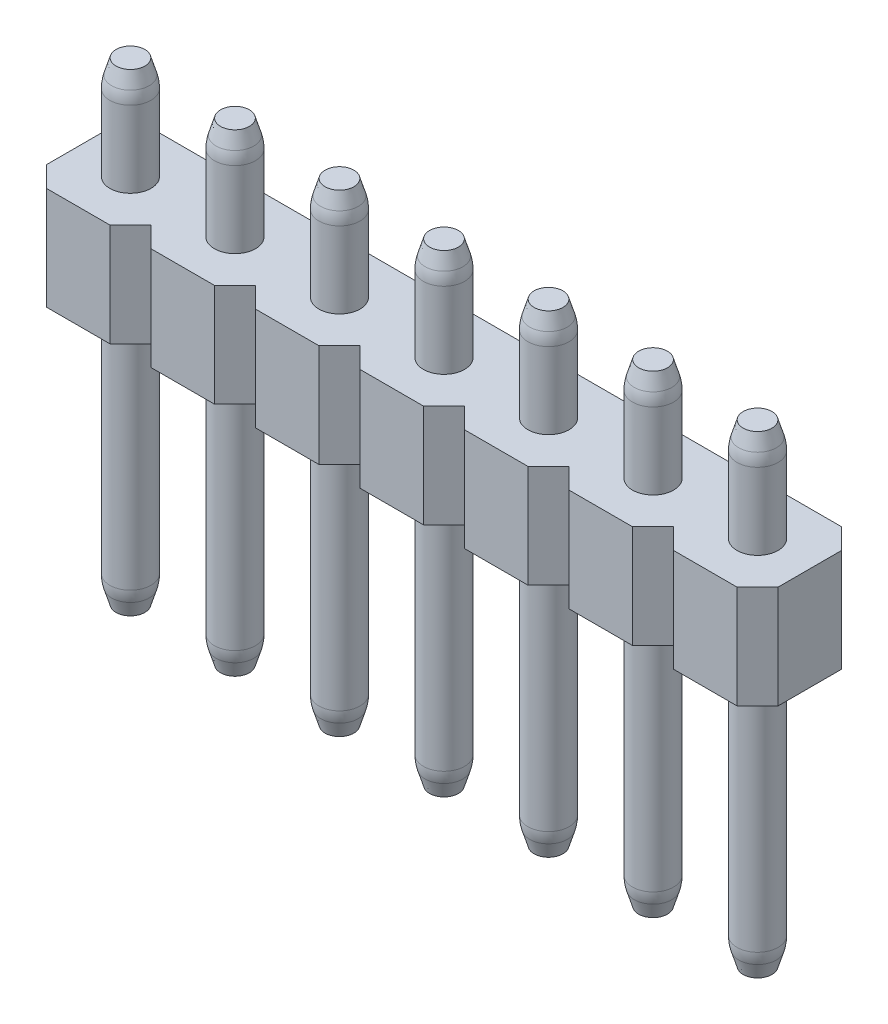
from build123d import *

# Parameters (mm, degrees)
SKETCH1_R               = 0.5
BOSS_EXTRUDE1_DEPTH     = 11.5
BOSS_EXTRUDE1_2_DEPTH   = 11.5
BOSS_EXTRUDE1_3_DEPTH   = 11.5
BOSS_EXTRUDE1_4_DEPTH   = 11.5
BOSS_EXTRUDE1_5_DEPTH   = 11.5
BOSS_EXTRUDE1_6_DEPTH   = 11.5
BOSS_EXTRUDE1_7_DEPTH   = 11.5
BOSS_EXTRUDE1_8_DEPTH   = 11.5
BOSS_EXTRUDE1_9_DEPTH   = 11.5
BOSS_EXTRUDE1_10_DEPTH  = 11.5
BOSS_EXTRUDE1_11_DEPTH  = 11.5
BOSS_EXTRUDE1_12_DEPTH  = 11.5
BOSS_EXTRUDE1_13_DEPTH  = 11.5
BOSS_EXTRUDE1_14_DEPTH  = 11.5
BOSS_EXTRUDE1_15_DEPTH  = 11.5
BOSS_EXTRUDE1_16_DEPTH  = 11.5
BOSS_EXTRUDE2_DEPTH     = 2.5
CHAMFER1_SIZE           = 0.5
CHAMFER1_SIZE2          = 0.15
CHAMFER1_PART_2_SIZE    = 0.5
CHAMFER1_PART_2_SIZE2   = 0.15
CHAMFER1_PART_3_SIZE    = 0.5
CHAMFER1_PART_3_SIZE2   = 0.15
CHAMFER1_PART_4_SIZE    = 0.5
CHAMFER1_PART_4_SIZE2   = 0.15
CHAMFER1_PART_5_SIZE    = 0.5
CHAMFER1_PART_5_SIZE2   = 0.15
CHAMFER1_PART_6_SIZE    = 0.5
CHAMFER1_PART_6_SIZE2   = 0.15
CHAMFER1_PART_7_SIZE    = 0.5
CHAMFER1_PART_7_SIZE2   = 0.15
CHAMFER1_PART_8_SIZE    = 0.5
CHAMFER1_PART_8_SIZE2   = 0.15
CHAMFER1_PART_9_SIZE    = 0.5
CHAMFER1_PART_9_SIZE2   = 0.15
CHAMFER1_PART_10_SIZE   = 0.5
CHAMFER1_PART_10_SIZE2  = 0.15
CHAMFER1_PART_11_SIZE   = 0.5
CHAMFER1_PART_11_SIZE2  = 0.15
CHAMFER1_PART_12_SIZE   = 0.5
CHAMFER1_PART_12_SIZE2  = 0.15
CHAMFER1_PART_13_SIZE   = 0.5
CHAMFER1_PART_13_SIZE2  = 0.15
CHAMFER1_PART_14_SIZE   = 0.5
CHAMFER1_PART_14_SIZE2  = 0.15
CHAMFER1_PART_15_SIZE   = 0.5
CHAMFER1_PART_15_SIZE2  = 0.15
CHAMFER1_PART_16_SIZE   = 0.5
CHAMFER1_PART_16_SIZE2  = 0.15
FILLET1_R               = 1
CHAMFER2_SIZE           = 0.15
CHAMFER2_SIZE2          = 0.5
CHAMFER2_PART_2_SIZE    = 0.15
CHAMFER2_PART_2_SIZE2   = 0.5
CHAMFER2_PART_3_SIZE    = 0.15
CHAMFER2_PART_3_SIZE2   = 0.5
CHAMFER2_PART_4_SIZE    = 0.15
CHAMFER2_PART_4_SIZE2   = 0.5
CHAMFER2_PART_5_SIZE    = 0.15
CHAMFER2_PART_5_SIZE2   = 0.5
CHAMFER2_PART_6_SIZE    = 0.15
CHAMFER2_PART_6_SIZE2   = 0.5
CHAMFER2_PART_7_SIZE    = 0.15
CHAMFER2_PART_7_SIZE2   = 0.5
CHAMFER2_PART_8_SIZE    = 0.15
CHAMFER2_PART_8_SIZE2   = 0.5
CHAMFER2_PART_9_SIZE    = 0.15
CHAMFER2_PART_9_SIZE2   = 0.5
CHAMFER2_PART_10_SIZE   = 0.15
CHAMFER2_PART_10_SIZE2  = 0.5
CHAMFER2_PART_11_SIZE   = 0.15
CHAMFER2_PART_11_SIZE2  = 0.5
CHAMFER2_PART_12_SIZE   = 0.15
CHAMFER2_PART_12_SIZE2  = 0.5
CHAMFER2_PART_13_SIZE   = 0.15
CHAMFER2_PART_13_SIZE2  = 0.5
CHAMFER2_PART_14_SIZE   = 0.15
CHAMFER2_PART_14_SIZE2  = 0.5
CHAMFER2_PART_15_SIZE   = 0.15
CHAMFER2_PART_15_SIZE2  = 0.5
CHAMFER2_PART_16_SIZE   = 0.15
CHAMFER2_PART_16_SIZE2  = 0.5
FILLET2_R               = 1
SKETCH3_W               = 22.86
SKETCH3_H               = 11.5
CUT_EXTRUDE1_DEPTH      = 1
CUT_EXTRUDE1_DEPTH_BACK = 3.54


with BuildPart() as part:
    # Sketch1 → Boss-Extrude1 (new body)
    with BuildSketch(Plane(origin=(0, 0, 0), x_dir=(1, 0, 0), z_dir=(0, 1, 0))):
        Circle(SKETCH1_R)
    extrude(amount=BOSS_EXTRUDE1_DEPTH)



with BuildPart() as body_2:
    # Sketch1 → Boss-Extrude1 2 (new body)
    with BuildSketch(Plane(origin=(0, 0, 0), x_dir=(1, 0, 0), z_dir=(0, 1, 0))):
        with Locations((2.54, 0)):
            Circle(SKETCH1_R)
    extrude(amount=BOSS_EXTRUDE1_2_DEPTH)


with BuildPart() as body_3:
    # Sketch1 → Boss-Extrude1 3 (new body)
    with BuildSketch(Plane(origin=(0, 0, 0), x_dir=(1, 0, 0), z_dir=(0, 1, 0))):
        with Locations((5.08, 0)):
            Circle(SKETCH1_R)
    extrude(amount=BOSS_EXTRUDE1_3_DEPTH)


with BuildPart() as body_4:
    # Sketch1 → Boss-Extrude1 4 (new body)
    with BuildSketch(Plane(origin=(0, 0, 0), x_dir=(1, 0, 0), z_dir=(0, 1, 0))):
        with Locations((7.62, 0)):
            Circle(SKETCH1_R)
    extrude(amount=BOSS_EXTRUDE1_4_DEPTH)


with BuildPart() as body_5:
    # Sketch1 → Boss-Extrude1 5 (new body)
    with BuildSketch(Plane(origin=(0, 0, 0), x_dir=(1, 0, 0), z_dir=(0, 1, 0))):
        with Locations((10.16, 0)):
            Circle(SKETCH1_R)
    extrude(amount=BOSS_EXTRUDE1_5_DEPTH)


with BuildPart() as body_6:
    # Sketch1 → Boss-Extrude1 6 (new body)
    with BuildSketch(Plane(origin=(0, 0, 0), x_dir=(1, 0, 0), z_dir=(0, 1, 0))):
        with Locations((12.7, 0)):
            Circle(SKETCH1_R)
    extrude(amount=BOSS_EXTRUDE1_6_DEPTH)


with BuildPart() as body_7:
    # Sketch1 → Boss-Extrude1 7 (new body)
    with BuildSketch(Plane(origin=(0, 0, 0), x_dir=(1, 0, 0), z_dir=(0, 1, 0))):
        with Locations((15.24, 0)):
            Circle(SKETCH1_R)
    extrude(amount=BOSS_EXTRUDE1_7_DEPTH)


with BuildPart() as body_8:
    # Sketch1 → Boss-Extrude1 8 (new body)
    with BuildSketch(Plane(origin=(0, 0, 0), x_dir=(1, 0, 0), z_dir=(0, 1, 0))):
        with Locations((17.78, 0)):
            Circle(SKETCH1_R)
    extrude(amount=BOSS_EXTRUDE1_8_DEPTH)


with BuildPart() as body_9:
    # Sketch1 → Boss-Extrude1 9 (new body)
    with BuildSketch(Plane(origin=(0, 0, 0), x_dir=(1, 0, 0), z_dir=(0, 1, 0))):
        with Locations((20.32, 0)):
            Circle(SKETCH1_R)
    extrude(amount=BOSS_EXTRUDE1_9_DEPTH)


with BuildPart() as body_10:
    # Sketch1 → Boss-Extrude1 10 (new body)
    with BuildSketch(Plane(origin=(0, 0, 0), x_dir=(1, 0, 0), z_dir=(0, 1, 0))):
        with Locations((22.86, 0)):
            Circle(SKETCH1_R)
    extrude(amount=BOSS_EXTRUDE1_10_DEPTH)


with BuildPart() as body_11:
    # Sketch1 → Boss-Extrude1 11 (new body)
    with BuildSketch(Plane(origin=(0, 0, 0), x_dir=(1, 0, 0), z_dir=(0, 1, 0))):
        with Locations((25.4, 0)):
            Circle(SKETCH1_R)
    extrude(amount=BOSS_EXTRUDE1_11_DEPTH)


with BuildPart() as body_12:
    # Sketch1 → Boss-Extrude1 12 (new body)
    with BuildSketch(Plane(origin=(0, 0, 0), x_dir=(1, 0, 0), z_dir=(0, 1, 0))):
        with Locations((27.94, 0)):
            Circle(SKETCH1_R)
    extrude(amount=BOSS_EXTRUDE1_12_DEPTH)


with BuildPart() as body_13:
    # Sketch1 → Boss-Extrude1 13 (new body)
    with BuildSketch(Plane(origin=(0, 0, 0), x_dir=(1, 0, 0), z_dir=(0, 1, 0))):
        with Locations((30.48, 0)):
            Circle(SKETCH1_R)
    extrude(amount=BOSS_EXTRUDE1_13_DEPTH)


with BuildPart() as body_14:
    # Sketch1 → Boss-Extrude1 14 (new body)
    with BuildSketch(Plane(origin=(0, 0, 0), x_dir=(1, 0, 0), z_dir=(0, 1, 0))):
        with Locations((33.02, 0)):
            Circle(SKETCH1_R)
    extrude(amount=BOSS_EXTRUDE1_14_DEPTH)


with BuildPart() as body_15:
    # Sketch1 → Boss-Extrude1 15 (new body)
    with BuildSketch(Plane(origin=(0, 0, 0), x_dir=(1, 0, 0), z_dir=(0, 1, 0))):
        with Locations((35.56, 0)):
            Circle(SKETCH1_R)
    extrude(amount=BOSS_EXTRUDE1_15_DEPTH)


with BuildPart() as body_16:
    # Sketch1 → Boss-Extrude1 16 (new body)
    with BuildSketch(Plane(origin=(0, 0, 0), x_dir=(1, 0, 0), z_dir=(0, 1, 0))):
        with Locations((38.1, 0)):
            Circle(SKETCH1_R)
    extrude(amount=BOSS_EXTRUDE1_16_DEPTH)


with BuildPart() as part_1:
    add(part.part)

    add(body_2.part)  # Boss-Extrude2 merges body 2

    add(body_3.part)  # Boss-Extrude2 merges body 3

    add(body_4.part)  # Boss-Extrude2 merges body 4

    add(body_5.part)  # Boss-Extrude2 merges body 5

    add(body_6.part)  # Boss-Extrude2 merges body 6

    add(body_7.part)  # Boss-Extrude2 merges body 7

    add(body_8.part)  # Boss-Extrude2 merges body 8

    add(body_9.part)  # Boss-Extrude2 merges body 9

    add(body_10.part)  # Boss-Extrude2 merges body 10

    add(body_11.part)  # Boss-Extrude2 merges body 11

    add(body_12.part)  # Boss-Extrude2 merges body 12

    add(body_13.part)  # Boss-Extrude2 merges body 13

    add(body_14.part)  # Boss-Extrude2 merges body 14

    add(body_15.part)  # Boss-Extrude2 merges body 15

    add(body_16.part)  # Boss-Extrude2 merges body 16
    # Sketch2 → Boss-Extrude2 (add)
    with BuildSketch(Plane(origin=(0, 6.5, 0), x_dir=(1, 0, 0), z_dir=(0, 1, 0))):
        Polygon((-1.27, 0.77), (-0.77, 1.27), (0.77, 1.27), (1.27, 0.77), (1.77, 1.27), (3.31, 1.27), (3.81, 0.77), (4.31, 1.27), (5.85, 1.27), (6.35, 0.77), (6.85, 1.27), (8.39, 1.27), (8.89, 0.77), (9.39, 1.27), (10.93, 1.27), (11.43, 0.77), (11.93, 1.27), (13.47, 1.27), (13.97, 0.77), (14.47, 1.27), (16.01, 1.27), (16.51, 0.77), (17.01, 1.27), (18.55, 1.27), (19.05, 0.77), (19.55, 1.27), (21.09, 1.27), (21.59, 0.77), (22.09, 1.27), (23.63, 1.27), (24.13, 0.77), (24.63, 1.27), (26.17, 1.27), (26.67, 0.77), (27.17, 1.27), (28.71, 1.27), (29.21, 0.77), (29.71, 1.27), (31.25, 1.27), (31.75, 0.77), (32.25, 1.27), (33.79, 1.27), (34.29, 0.77), (34.79, 1.27), (36.33, 1.27), (36.83, 0.77), (37.33, 1.27), (38.87, 1.27), (39.37, 0.77), (39.37, -0.77), (38.87, -1.27), (37.33, -1.27), (36.83, -0.77), (36.33, -1.27), (34.79, -1.27), (34.29, -0.77), (33.79, -1.27), (32.25, -1.27), (31.75, -0.77), (31.25, -1.27), (29.71, -1.27), (29.21, -0.77), (28.71, -1.27), (27.17, -1.27), (26.67, -0.77), (26.17, -1.27), (24.63, -1.27), (24.13, -0.77), (23.63, -1.27), (22.09, -1.27), (21.59, -0.77), (21.09, -1.27), (19.55, -1.27), (19.05, -0.77), (18.55, -1.27), (17.01, -1.27), (16.51, -0.77), (16.01, -1.27), (14.47, -1.27), (13.97, -0.77), (13.47, -1.27), (11.93, -1.27), (11.43, -0.77), (10.93, -1.27), (9.39, -1.27), (8.89, -0.77), (8.39, -1.27), (6.85, -1.27), (6.35, -0.77), (5.85, -1.27), (4.31, -1.27), (3.81, -0.77), (3.31, -1.27), (1.77, -1.27), (1.27, -0.77), (0.77, -1.27), (-0.77, -1.27), (-1.27, -0.77), align=None)
    extrude(amount=BOSS_EXTRUDE2_DEPTH)

    # Chamfer1
    chamfer1_edges = [part_1.edges().sort_by_distance(p)[0] for p in [
        (2.04, 11.5, 0),
    ]]
    chamfer1_side = [part_1.faces().sort_by_distance(p)[0] for p in [
        (2.04, 10.25, 0),
    ]]
    chamfer(chamfer1_edges, length=CHAMFER1_SIZE, length2=CHAMFER1_SIZE2, reference=chamfer1_side[0])

    # Chamfer1 part 2
    chamfer1_part_2_edges = [part_1.edges().sort_by_distance(p)[0] for p in [
        (4.58, 11.5, 0),
    ]]
    chamfer1_part_2_side = [part_1.faces().sort_by_distance(p)[0] for p in [
        (4.58, 10.25, 0),
    ]]
    chamfer(chamfer1_part_2_edges, length=CHAMFER1_PART_2_SIZE, length2=CHAMFER1_PART_2_SIZE2, reference=chamfer1_part_2_side[0])

    # Chamfer1 part 3
    chamfer1_part_3_edges = [part_1.edges().sort_by_distance(p)[0] for p in [
        (7.12, 11.5, 0),
    ]]
    chamfer1_part_3_side = [part_1.faces().sort_by_distance(p)[0] for p in [
        (7.12, 10.25, 0),
    ]]
    chamfer(chamfer1_part_3_edges, length=CHAMFER1_PART_3_SIZE, length2=CHAMFER1_PART_3_SIZE2, reference=chamfer1_part_3_side[0])

    # Chamfer1 part 4
    chamfer1_part_4_edges = [part_1.edges().sort_by_distance(p)[0] for p in [
        (9.66, 11.5, 0),
    ]]
    chamfer1_part_4_side = [part_1.faces().sort_by_distance(p)[0] for p in [
        (9.66, 10.25, 0),
    ]]
    chamfer(chamfer1_part_4_edges, length=CHAMFER1_PART_4_SIZE, length2=CHAMFER1_PART_4_SIZE2, reference=chamfer1_part_4_side[0])

    # Chamfer1 part 5
    chamfer1_part_5_edges = [part_1.edges().sort_by_distance(p)[0] for p in [
        (12.2, 11.5, 0),
    ]]
    chamfer1_part_5_side = [part_1.faces().sort_by_distance(p)[0] for p in [
        (12.2, 10.25, 0),
    ]]
    chamfer(chamfer1_part_5_edges, length=CHAMFER1_PART_5_SIZE, length2=CHAMFER1_PART_5_SIZE2, reference=chamfer1_part_5_side[0])

    # Chamfer1 part 6
    chamfer1_part_6_edges = [part_1.edges().sort_by_distance(p)[0] for p in [
        (14.74, 11.5, 0),
    ]]
    chamfer1_part_6_side = [part_1.faces().sort_by_distance(p)[0] for p in [
        (14.74, 10.25, 0),
    ]]
    chamfer(chamfer1_part_6_edges, length=CHAMFER1_PART_6_SIZE, length2=CHAMFER1_PART_6_SIZE2, reference=chamfer1_part_6_side[0])

    # Chamfer1 part 7
    chamfer1_part_7_edges = [part_1.edges().sort_by_distance(p)[0] for p in [
        (17.28, 11.5, 0),
    ]]
    chamfer1_part_7_side = [part_1.faces().sort_by_distance(p)[0] for p in [
        (17.28, 10.25, 0),
    ]]
    chamfer(chamfer1_part_7_edges, length=CHAMFER1_PART_7_SIZE, length2=CHAMFER1_PART_7_SIZE2, reference=chamfer1_part_7_side[0])

    # Chamfer1 part 8
    chamfer1_part_8_edges = [part_1.edges().sort_by_distance(p)[0] for p in [
        (19.82, 11.5, 0),
    ]]
    chamfer1_part_8_side = [part_1.faces().sort_by_distance(p)[0] for p in [
        (19.82, 10.25, 0),
    ]]
    chamfer(chamfer1_part_8_edges, length=CHAMFER1_PART_8_SIZE, length2=CHAMFER1_PART_8_SIZE2, reference=chamfer1_part_8_side[0])

    # Chamfer1 part 9
    chamfer1_part_9_edges = [part_1.edges().sort_by_distance(p)[0] for p in [
        (22.36, 11.5, 0),
    ]]
    chamfer1_part_9_side = [part_1.faces().sort_by_distance(p)[0] for p in [
        (22.36, 10.25, 0),
    ]]
    chamfer(chamfer1_part_9_edges, length=CHAMFER1_PART_9_SIZE, length2=CHAMFER1_PART_9_SIZE2, reference=chamfer1_part_9_side[0])

    # Chamfer1 part 10
    chamfer1_part_10_edges = [part_1.edges().sort_by_distance(p)[0] for p in [
        (24.9, 11.5, 0),
    ]]
    chamfer1_part_10_side = [part_1.faces().sort_by_distance(p)[0] for p in [
        (24.9, 10.25, 0),
    ]]
    chamfer(chamfer1_part_10_edges, length=CHAMFER1_PART_10_SIZE, length2=CHAMFER1_PART_10_SIZE2, reference=chamfer1_part_10_side[0])

    # Chamfer1 part 11
    chamfer1_part_11_edges = [part_1.edges().sort_by_distance(p)[0] for p in [
        (27.44, 11.5, 0),
    ]]
    chamfer1_part_11_side = [part_1.faces().sort_by_distance(p)[0] for p in [
        (27.44, 10.25, 0),
    ]]
    chamfer(chamfer1_part_11_edges, length=CHAMFER1_PART_11_SIZE, length2=CHAMFER1_PART_11_SIZE2, reference=chamfer1_part_11_side[0])

    # Chamfer1 part 12
    chamfer1_part_12_edges = [part_1.edges().sort_by_distance(p)[0] for p in [
        (29.98, 11.5, 0),
    ]]
    chamfer1_part_12_side = [part_1.faces().sort_by_distance(p)[0] for p in [
        (29.98, 10.25, 0),
    ]]
    chamfer(chamfer1_part_12_edges, length=CHAMFER1_PART_12_SIZE, length2=CHAMFER1_PART_12_SIZE2, reference=chamfer1_part_12_side[0])

    # Chamfer1 part 13
    chamfer1_part_13_edges = [part_1.edges().sort_by_distance(p)[0] for p in [
        (32.52, 11.5, 0),
    ]]
    chamfer1_part_13_side = [part_1.faces().sort_by_distance(p)[0] for p in [
        (32.52, 10.25, 0),
    ]]
    chamfer(chamfer1_part_13_edges, length=CHAMFER1_PART_13_SIZE, length2=CHAMFER1_PART_13_SIZE2, reference=chamfer1_part_13_side[0])

    # Chamfer1 part 14
    chamfer1_part_14_edges = [part_1.edges().sort_by_distance(p)[0] for p in [
        (35.06, 11.5, 0),
    ]]
    chamfer1_part_14_side = [part_1.faces().sort_by_distance(p)[0] for p in [
        (35.06, 10.25, 0),
    ]]
    chamfer(chamfer1_part_14_edges, length=CHAMFER1_PART_14_SIZE, length2=CHAMFER1_PART_14_SIZE2, reference=chamfer1_part_14_side[0])

    # Chamfer1 part 15
    chamfer1_part_15_edges = [part_1.edges().sort_by_distance(p)[0] for p in [
        (37.6, 11.5, 0),
    ]]
    chamfer1_part_15_side = [part_1.faces().sort_by_distance(p)[0] for p in [
        (37.6, 10.25, 0),
    ]]
    chamfer(chamfer1_part_15_edges, length=CHAMFER1_PART_15_SIZE, length2=CHAMFER1_PART_15_SIZE2, reference=chamfer1_part_15_side[0])

    # Chamfer1 part 16
    chamfer1_part_16_edges = [part_1.edges().sort_by_distance(p)[0] for p in [
        (-0.5, 11.5, 0),
    ]]
    chamfer1_part_16_side = [part_1.faces().sort_by_distance(p)[0] for p in [
        (-0.5, 10.25, 0),
    ]]
    chamfer(chamfer1_part_16_edges, length=CHAMFER1_PART_16_SIZE, length2=CHAMFER1_PART_16_SIZE2, reference=chamfer1_part_16_side[0])

    # Fillet1
    fillet1_edges = [part_1.edges().sort_by_distance(p)[0] for p in [
        (37.6, 11, 0),
        (35.06, 11, 0),
        (32.52, 11, 0),
        (29.98, 11, 0),
        (27.44, 11, 0),
        (24.9, 11, 0),
        (22.36, 11, 0),
        (19.82, 11, 0),
        (17.28, 11, 0),
        (14.74, 11, 0),
        (12.2, 11, 0),
        (9.66, 11, 0),
        (7.12, 11, 0),
        (4.58, 11, 0),
        (2.04, 11, 0),
        (-0.5, 11, 0),
    ]]
    fillet(fillet1_edges, radius=FILLET1_R)

    # Chamfer2
    chamfer2_edges = [part_1.edges().sort_by_distance(p)[0] for p in [
        (-0.5, 0, 0),
    ]]
    chamfer2_side = [part_1.faces().sort_by_distance(p)[0] for p in [
        (0, 0, 0),
    ]]
    chamfer(chamfer2_edges, length=CHAMFER2_SIZE, length2=CHAMFER2_SIZE2, reference=chamfer2_side[0])

    # Chamfer2 part 2
    chamfer2_part_2_edges = [part_1.edges().sort_by_distance(p)[0] for p in [
        (2.04, 0, 0),
    ]]
    chamfer2_part_2_side = [part_1.faces().sort_by_distance(p)[0] for p in [
        (2.54, 0, 0),
    ]]
    chamfer(chamfer2_part_2_edges, length=CHAMFER2_PART_2_SIZE, length2=CHAMFER2_PART_2_SIZE2, reference=chamfer2_part_2_side[0])

    # Chamfer2 part 3
    chamfer2_part_3_edges = [part_1.edges().sort_by_distance(p)[0] for p in [
        (4.58, 0, 0),
    ]]
    chamfer2_part_3_side = [part_1.faces().sort_by_distance(p)[0] for p in [
        (5.08, 0, 0),
    ]]
    chamfer(chamfer2_part_3_edges, length=CHAMFER2_PART_3_SIZE, length2=CHAMFER2_PART_3_SIZE2, reference=chamfer2_part_3_side[0])

    # Chamfer2 part 4
    chamfer2_part_4_edges = [part_1.edges().sort_by_distance(p)[0] for p in [
        (7.12, 0, 0),
    ]]
    chamfer2_part_4_side = [part_1.faces().sort_by_distance(p)[0] for p in [
        (7.62, 0, 0),
    ]]
    chamfer(chamfer2_part_4_edges, length=CHAMFER2_PART_4_SIZE, length2=CHAMFER2_PART_4_SIZE2, reference=chamfer2_part_4_side[0])

    # Chamfer2 part 5
    chamfer2_part_5_edges = [part_1.edges().sort_by_distance(p)[0] for p in [
        (9.66, 0, 0),
    ]]
    chamfer2_part_5_side = [part_1.faces().sort_by_distance(p)[0] for p in [
        (10.16, 0, 0),
    ]]
    chamfer(chamfer2_part_5_edges, length=CHAMFER2_PART_5_SIZE, length2=CHAMFER2_PART_5_SIZE2, reference=chamfer2_part_5_side[0])

    # Chamfer2 part 6
    chamfer2_part_6_edges = [part_1.edges().sort_by_distance(p)[0] for p in [
        (12.2, 0, 0),
    ]]
    chamfer2_part_6_side = [part_1.faces().sort_by_distance(p)[0] for p in [
        (12.7, 0, 0),
    ]]
    chamfer(chamfer2_part_6_edges, length=CHAMFER2_PART_6_SIZE, length2=CHAMFER2_PART_6_SIZE2, reference=chamfer2_part_6_side[0])

    # Chamfer2 part 7
    chamfer2_part_7_edges = [part_1.edges().sort_by_distance(p)[0] for p in [
        (14.74, 0, 0),
    ]]
    chamfer2_part_7_side = [part_1.faces().sort_by_distance(p)[0] for p in [
        (15.24, 0, 0),
    ]]
    chamfer(chamfer2_part_7_edges, length=CHAMFER2_PART_7_SIZE, length2=CHAMFER2_PART_7_SIZE2, reference=chamfer2_part_7_side[0])

    # Chamfer2 part 8
    chamfer2_part_8_edges = [part_1.edges().sort_by_distance(p)[0] for p in [
        (17.28, 0, 0),
    ]]
    chamfer2_part_8_side = [part_1.faces().sort_by_distance(p)[0] for p in [
        (17.78, 0, 0),
    ]]
    chamfer(chamfer2_part_8_edges, length=CHAMFER2_PART_8_SIZE, length2=CHAMFER2_PART_8_SIZE2, reference=chamfer2_part_8_side[0])

    # Chamfer2 part 9
    chamfer2_part_9_edges = [part_1.edges().sort_by_distance(p)[0] for p in [
        (19.82, 0, 0),
    ]]
    chamfer2_part_9_side = [part_1.faces().sort_by_distance(p)[0] for p in [
        (20.32, 0, 0),
    ]]
    chamfer(chamfer2_part_9_edges, length=CHAMFER2_PART_9_SIZE, length2=CHAMFER2_PART_9_SIZE2, reference=chamfer2_part_9_side[0])

    # Chamfer2 part 10
    chamfer2_part_10_edges = [part_1.edges().sort_by_distance(p)[0] for p in [
        (22.36, 0, 0),
    ]]
    chamfer2_part_10_side = [part_1.faces().sort_by_distance(p)[0] for p in [
        (22.86, 0, 0),
    ]]
    chamfer(chamfer2_part_10_edges, length=CHAMFER2_PART_10_SIZE, length2=CHAMFER2_PART_10_SIZE2, reference=chamfer2_part_10_side[0])

    # Chamfer2 part 11
    chamfer2_part_11_edges = [part_1.edges().sort_by_distance(p)[0] for p in [
        (24.9, 0, 0),
    ]]
    chamfer2_part_11_side = [part_1.faces().sort_by_distance(p)[0] for p in [
        (25.4, 0, 0),
    ]]
    chamfer(chamfer2_part_11_edges, length=CHAMFER2_PART_11_SIZE, length2=CHAMFER2_PART_11_SIZE2, reference=chamfer2_part_11_side[0])

    # Chamfer2 part 12
    chamfer2_part_12_edges = [part_1.edges().sort_by_distance(p)[0] for p in [
        (27.44, 0, 0),
    ]]
    chamfer2_part_12_side = [part_1.faces().sort_by_distance(p)[0] for p in [
        (27.94, 0, 0),
    ]]
    chamfer(chamfer2_part_12_edges, length=CHAMFER2_PART_12_SIZE, length2=CHAMFER2_PART_12_SIZE2, reference=chamfer2_part_12_side[0])

    # Chamfer2 part 13
    chamfer2_part_13_edges = [part_1.edges().sort_by_distance(p)[0] for p in [
        (29.98, 0, 0),
    ]]
    chamfer2_part_13_side = [part_1.faces().sort_by_distance(p)[0] for p in [
        (30.48, 0, 0),
    ]]
    chamfer(chamfer2_part_13_edges, length=CHAMFER2_PART_13_SIZE, length2=CHAMFER2_PART_13_SIZE2, reference=chamfer2_part_13_side[0])

    # Chamfer2 part 14
    chamfer2_part_14_edges = [part_1.edges().sort_by_distance(p)[0] for p in [
        (32.52, 0, 0),
    ]]
    chamfer2_part_14_side = [part_1.faces().sort_by_distance(p)[0] for p in [
        (33.02, 0, 0),
    ]]
    chamfer(chamfer2_part_14_edges, length=CHAMFER2_PART_14_SIZE, length2=CHAMFER2_PART_14_SIZE2, reference=chamfer2_part_14_side[0])

    # Chamfer2 part 15
    chamfer2_part_15_edges = [part_1.edges().sort_by_distance(p)[0] for p in [
        (35.06, 0, 0),
    ]]
    chamfer2_part_15_side = [part_1.faces().sort_by_distance(p)[0] for p in [
        (35.56, 0, 0),
    ]]
    chamfer(chamfer2_part_15_edges, length=CHAMFER2_PART_15_SIZE, length2=CHAMFER2_PART_15_SIZE2, reference=chamfer2_part_15_side[0])

    # Chamfer2 part 16
    chamfer2_part_16_edges = [part_1.edges().sort_by_distance(p)[0] for p in [
        (37.6, 0, 0),
    ]]
    chamfer2_part_16_side = [part_1.faces().sort_by_distance(p)[0] for p in [
        (38.1, 0, 0),
    ]]
    chamfer(chamfer2_part_16_edges, length=CHAMFER2_PART_16_SIZE, length2=CHAMFER2_PART_16_SIZE2, reference=chamfer2_part_16_side[0])

    # Fillet2
    fillet2_edges = [part_1.edges().sort_by_distance(p)[0] for p in [
        (9.66, 0.5, 0),
        (17.28, 0.5, 0),
        (22.36, 0.5, 0),
        (27.44, 0.5, 0),
        (29.98, 0.5, 0),
        (-0.5, 0.5, 0),
        (2.04, 0.5, 0),
        (4.58, 0.5, 0),
        (7.12, 0.5, 0),
        (12.2, 0.5, 0),
        (14.74, 0.5, 0),
        (19.82, 0.5, 0),
        (24.9, 0.5, 0),
        (32.52, 0.5, 0),
        (35.06, 0.5, 0),
        (37.6, 0.5, 0),
    ]]
    fillet(fillet2_edges, radius=FILLET2_R)

    # Sketch3 → Cut-Extrude1 (cut, two sides)
    with BuildSketch(Plane.XY.offset(1.27)) as cut_extrude1_sk:
        with Locations((27.94, 5.75)):
            Rectangle(SKETCH3_W, SKETCH3_H)
    extrude(amount=CUT_EXTRUDE1_DEPTH, mode=Mode.SUBTRACT)
    extrude(cut_extrude1_sk.sketch, amount=-CUT_EXTRUDE1_DEPTH_BACK, mode=Mode.SUBTRACT)


solid = part_1.part
